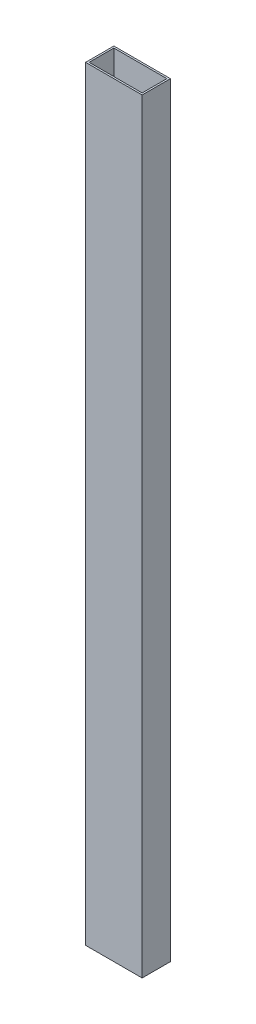
from build123d import *

# Parameters (mm, degrees)
SKETCH1_W           = 50.8
SKETCH1_H           = 25.4
SKETCH1_W_2         = 47.625
SKETCH1_H_2         = 22.225
BOSS_EXTRUDE1_DEPTH = 687.07


with BuildPart() as part:
    # Sketch1 → Boss-Extrude1 (new body)
    with BuildSketch(Plane(origin=(0, 0, 0), x_dir=(1, 0, 0), z_dir=(0, 1, 0))):
        with Locations((12.272596154, -7.845913462)):
            Rectangle(SKETCH1_W, SKETCH1_H)
        with Locations((12.272596154, -7.845913462)):
            Rectangle(SKETCH1_W_2, SKETCH1_H_2, mode=Mode.SUBTRACT)
    extrude(amount=BOSS_EXTRUDE1_DEPTH)


solid = part.part
